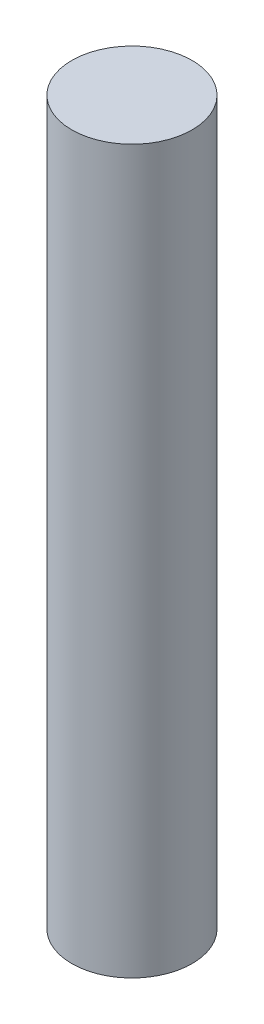
from build123d import *

# Parameters (mm, degrees)
SKETCH1_R           = 3.75
BOSS_EXTRUDE1_DEPTH = 45


with BuildPart() as part:
    # Sketch1 → Boss-Extrude1 (new body)
    with BuildSketch(Plane(origin=(0, 0, 0), x_dir=(1, 0, 0), z_dir=(0, 1, 0))):
        with Locations((-9.545454545, -4.431818182)):
            Circle(SKETCH1_R)
    extrude(amount=BOSS_EXTRUDE1_DEPTH)


solid = part.part
